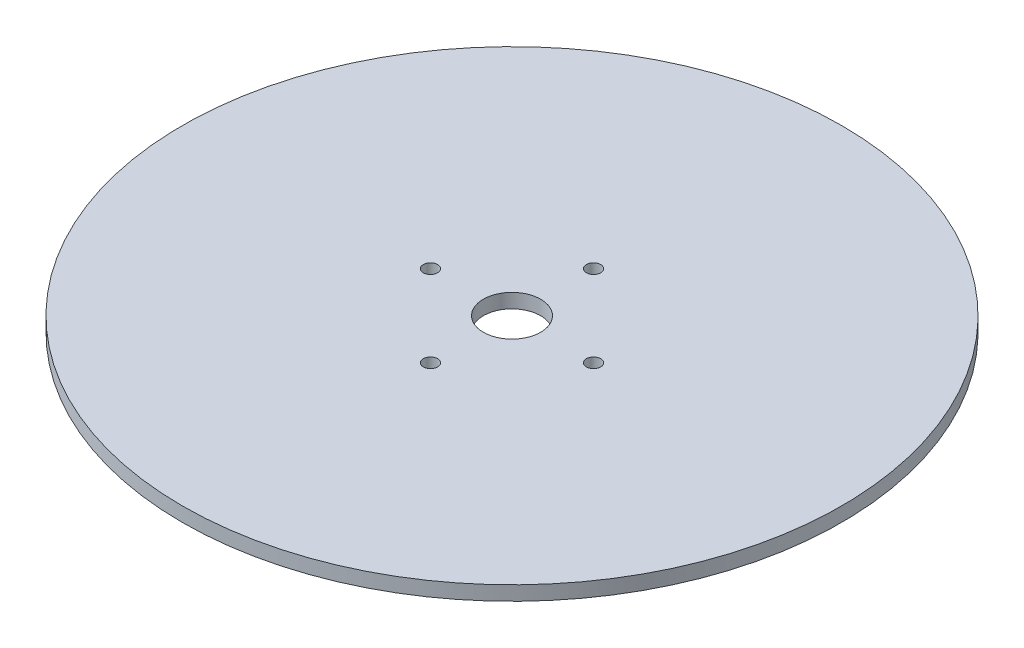
from build123d import *

# Parameters (mm, degrees)
SKETCH1_R           = 146.05
SKETCH1_R_2         = 12.7
SKETCH1_R_3         = 3.175
BOSS_EXTRUDE1_DEPTH = 6.35


with BuildPart() as part:
    # Sketch1 → Boss-Extrude1 (new body)
    with BuildSketch(Plane(origin=(0, 0, 0), x_dir=(1, 0, 0), z_dir=(0, 1, 0))):
        Circle(SKETCH1_R)
        Circle(SKETCH1_R_2, mode=Mode.SUBTRACT)
        with Locations((0, 36.1315)):
            Circle(SKETCH1_R_3, mode=Mode.SUBTRACT)
        with Locations((36.1315, 0)):
            Circle(SKETCH1_R_3, mode=Mode.SUBTRACT)
        with Locations((0, -36.1315)):
            Circle(SKETCH1_R_3, mode=Mode.SUBTRACT)
        with Locations((-36.1315, 0)):
            Circle(SKETCH1_R_3, mode=Mode.SUBTRACT)
    extrude(amount=BOSS_EXTRUDE1_DEPTH)


solid = part.part
